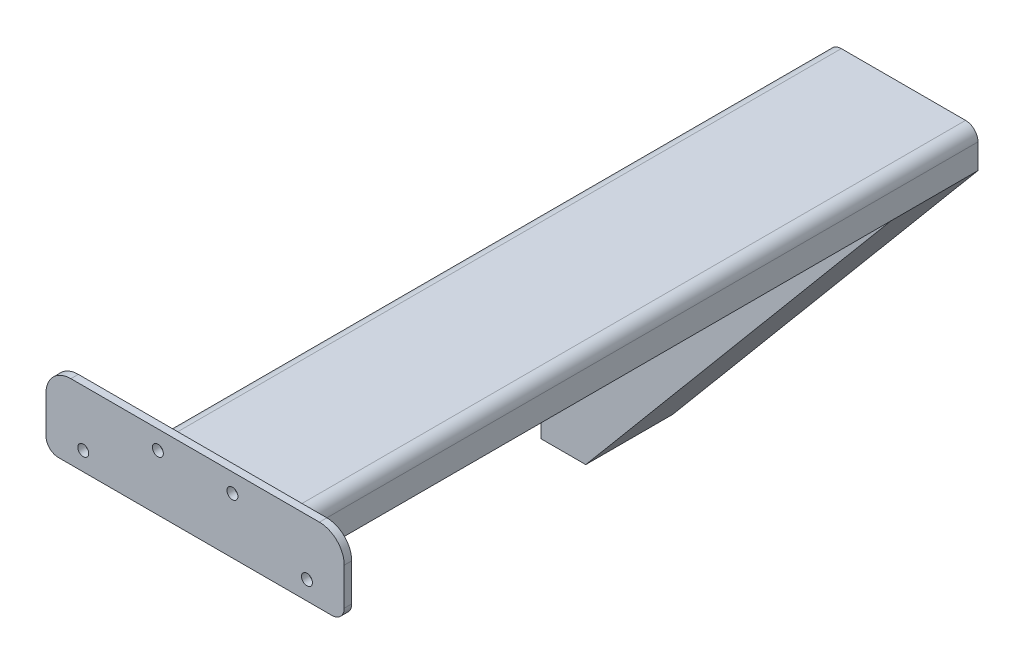
from build123d import *

# Parameters (mm, degrees)
BOSS_EXTRUDE1_DEPTH = 35
SKETCH5_W           = 40
SKETCH5_H           = 35
SKETCH5_W_2         = 20
BOSS_EXTRUDE4_DEPTH = 5
BOSS_EXTRUDE5_DEPTH = 35
CUT_EXTRUDE2_DEPTH  = 15
CUT_EXTRUDE3_DEPTH  = 10
SKETCH9_W           = 60
SKETCH9_H           = 15
BOSS_EXTRUDE6_DEPTH = 285
SKETCH10_W          = 35
SKETCH10_H          = 5
CUT_EXTRUDE4_DEPTH  = 250
SKETCH11_W          = 35
SKETCH11_H          = 5
CUT_EXTRUDE5_DEPTH  = 250
SKETCH12_W          = 30
SKETCH12_H          = 15
BOSS_EXTRUDE7_DEPTH = 3
FILLET1_R           = 5
FILLET2_R           = 5
SKETCH13_R          = 2.2
CUT_EXTRUDE6_DEPTH  = 10
SKETCH15_W          = 120
SKETCH15_H          = 15
BOSS_EXTRUDE8_DEPTH = 3
SKETCH16_R          = 2.2
CUT_EXTRUDE7_DEPTH  = 5
FILLET3_R           = 10
FILLET4_R           = 5


with BuildPart() as part:
    # Sketch1 → Boss-Extrude1 (new body)
    with BuildSketch(Plane.XY):
        Polygon((39.235591649, -231.893482393), (39.235591649, -281.893482393), (57.280610091, -281.893482393), (184.29867845, -130.519243102), (124.29867845, -130.519243102), align=None)
    extrude(amount=BOSS_EXTRUDE1_DEPTH)

    # Sketch5 → Boss-Extrude4 (add)
    with BuildSketch(Plane(origin=(0, -130.519243102, 0), x_dir=(1, 0, 0), z_dir=(0, 1, 0))):
        with Locations((104.29867845, -17.5)):
            Rectangle(SKETCH5_W, SKETCH5_H)
        with Locations((194.29867845, -17.5)):
            Rectangle(SKETCH5_W_2, SKETCH5_H)
    extrude(amount=-BOSS_EXTRUDE4_DEPTH)

    # Sketch6 → Boss-Extrude5 (add)
    with BuildSketch(Plane.XY.offset(35)):
        Polygon((184.29867845, -130.519243102), (184.29867845, -135.519243102), (180.103180294, -135.519243102), align=None)
    extrude(amount=-BOSS_EXTRUDE5_DEPTH)

    # Sketch7 → Cut-Extrude2 (cut)
    with BuildSketch(Plane.ZY.offset(-39.235591649)):
        Polygon((21.974103074, -266.942482427), (25.67459308, -264.253919063), (27.961621679, -260.292669331), (28.439740849, -255.743669297), (27.026279442, -251.393482393), (23.965637775, -247.994295455), (19.787028599, -246.133858785), (15.212971401, -246.133858785), (11.034362225, -247.994295455), (7.973720558, -251.393482393), (6.560259151, -255.743669297), (7.038378321, -260.292669331), (9.32540692, -264.253919063), (13.025896926, -266.942482427), (17.5, -267.893482393), align=None)
    extrude(amount=-CUT_EXTRUDE2_DEPTH, mode=Mode.SUBTRACT)

    # Sketch8 → Cut-Extrude3 (cut)
    with BuildSketch(Plane.XZ.offset(135.519243102)):
        with BuildLine():
            ThreePointArc((103.73838358, 19.002908699), (102.200929372, 19.65), (100.663475163, 19.002908699))
            Line((100.663475163, 19.002908699), (102.200929372, 17.5))
            Line((102.200929372, 17.5), (103.73838358, 19.002908699))
        make_face()
        with BuildLine():
            Line((102.200929372, 17.5), (100.663475163, 19.002908699))
            ThreePointArc((100.663475163, 19.002908699), (100.050929372, 17.5), (100.663475163, 15.997091301))
            Line((100.663475163, 15.997091301), (102.200929372, 17.5))
        make_face()
        with BuildLine():
            ThreePointArc((104.350929372, 17.5), (104.191912363, 18.31147195), (103.73838358, 19.002908699))
            Line((103.73838358, 19.002908699), (102.200929372, 17.5))
            Line((102.200929372, 17.5), (103.73838358, 15.997091301))
            ThreePointArc((103.73838358, 15.997091301), (104.191912363, 16.68852805), (104.350929372, 17.5))
        make_face()
        with BuildLine():
            Line((102.200929372, 17.5), (100.663475163, 15.997091301))
            ThreePointArc((100.663475163, 15.997091301), (102.200929372, 15.35), (103.73838358, 15.997091301))
            Line((103.73838358, 15.997091301), (102.200929372, 17.5))
        make_face()
        with BuildLine():
            ThreePointArc((193.423525745, 19.268546892), (192.200929372, 19.65), (190.978332999, 19.268546892))
            Line((190.978332999, 19.268546892), (192.200929372, 17.5))
            Line((192.200929372, 17.5), (193.423525745, 19.268546892))
        make_face()
        with BuildLine():
            Line((192.200929372, 17.5), (190.978332999, 19.268546892))
            ThreePointArc((190.978332999, 19.268546892), (190.050929372, 17.5), (190.978332999, 15.731453108))
            Line((190.978332999, 15.731453108), (192.200929372, 17.5))
        make_face()
        with BuildLine():
            Line((193.423525745, 19.268546892), (192.200929372, 17.5))
            Line((192.200929372, 17.5), (193.423525745, 15.731453108))
            ThreePointArc((193.423525745, 15.731453108), (194.105014743, 16.501521708), (194.350929372, 17.5))
            ThreePointArc((194.350929372, 17.5), (194.105014743, 18.498478292), (193.423525745, 19.268546892))
        make_face()
        with BuildLine():
            Line((193.423525745, 15.731453108), (192.200929372, 17.5))
            Line((192.200929372, 17.5), (190.978332999, 15.731453108))
            ThreePointArc((190.978332999, 15.731453108), (192.200929372, 15.35), (193.423525745, 15.731453108))
        make_face()
    extrude(amount=-CUT_EXTRUDE3_DEPTH, mode=Mode.SUBTRACT)

    # Sketch9 → Boss-Extrude6 (add)
    with BuildSketch(Plane(origin=(0, 0, 0), x_dir=(-1, 0, 0), z_dir=(0, 0, -1))):
        with Locations((-150.103180294, -128.019243102)):
            Rectangle(SKETCH9_W, SKETCH9_H)
    extrude(amount=-BOSS_EXTRUDE6_DEPTH)

    # Sketch10 → Cut-Extrude4 (cut)
    with BuildSketch(Plane(origin=(180.103180294, 0, 0), x_dir=(0, 0, -1), z_dir=(1, 0, 0))):
        with Locations((-17.5, -133.019243102)):
            Rectangle(SKETCH10_W, SKETCH10_H)
    extrude(amount=CUT_EXTRUDE4_DEPTH, mode=Mode.SUBTRACT)

    # Sketch11 → Cut-Extrude5 (cut)
    with BuildSketch(Plane.ZY.offset(-120.103180294)):
        with Locations((17.5, -133.019243102)):
            Rectangle(SKETCH11_W, SKETCH11_H)
    extrude(amount=CUT_EXTRUDE5_DEPTH, mode=Mode.SUBTRACT)

    # Sketch12 → Boss-Extrude7 (add)
    with BuildSketch(Plane.XY.offset(285)):
        with Locations((105.103180294, -128.019243102)):
            Rectangle(SKETCH12_W, SKETCH12_H)
        with Locations((195.103180294, -128.019243102)):
            Rectangle(SKETCH12_W, SKETCH12_H)
    extrude(amount=-BOSS_EXTRUDE7_DEPTH)

    # Fillet1
    fillet1_edges = [part.edges().sort_by_distance(p)[0] for p in [
        (120.103180294, -135.519243102, 17.5),
    ]]
    fillet(fillet1_edges, radius=FILLET1_R)

    # Fillet2
    fillet2_edges = [part.edges().sort_by_distance(p)[0] for p in [
        (120.103180294, -120.519243102, 141),
        (180.103180294, -120.519243102, 141),
    ]]
    fillet(fillet2_edges, radius=FILLET2_R)

    # Sketch13 → Cut-Extrude6 (cut)
    with BuildSketch(Plane(origin=(0, 0, 282), x_dir=(-1, 0, 0), z_dir=(0, 0, -1))):
        with Locations((-105.103180294, -128.019243102)):
            Circle(SKETCH13_R)
        with Locations((-195.103180294, -128.019243102)):
            Circle(SKETCH13_R)
    extrude(amount=-CUT_EXTRUDE6_DEPTH, mode=Mode.SUBTRACT)

    # Sketch15 → Boss-Extrude8 (add)
    with BuildSketch(Plane(origin=(0, 0, 282), x_dir=(-1, 0, 0), z_dir=(0, 0, -1))):
        with Locations((-150.103180294, -113.019243102)):
            Rectangle(SKETCH15_W, SKETCH15_H)
    extrude(amount=-BOSS_EXTRUDE8_DEPTH)

    # Sketch16 → Cut-Extrude7 (cut)
    with BuildSketch(Plane(origin=(0, 0, 282), x_dir=(-1, 0, 0), z_dir=(0, 0, -1))):
        with Locations((-165.103180294, -113.019243102)):
            Circle(SKETCH16_R)
        with Locations((-135.103180294, -113.019243102)):
            Circle(SKETCH16_R)
    extrude(amount=-CUT_EXTRUDE7_DEPTH, mode=Mode.SUBTRACT)

    # Fillet3
    fillet3_edges = [part.edges().sort_by_distance(p)[0] for p in [
        (210.103180294, -105.519243102, 283.5),
        (90.103180294, -105.519243102, 283.5),
    ]]
    fillet(fillet3_edges, radius=FILLET3_R)

    # Fillet4
    fillet4_edges = [part.edges().sort_by_distance(p)[0] for p in [
        (90.103180294, -135.519243102, 283.5),
        (210.103180294, -135.519243102, 283.5),
    ]]
    fillet(fillet4_edges, radius=FILLET4_R)


solid = part.part
